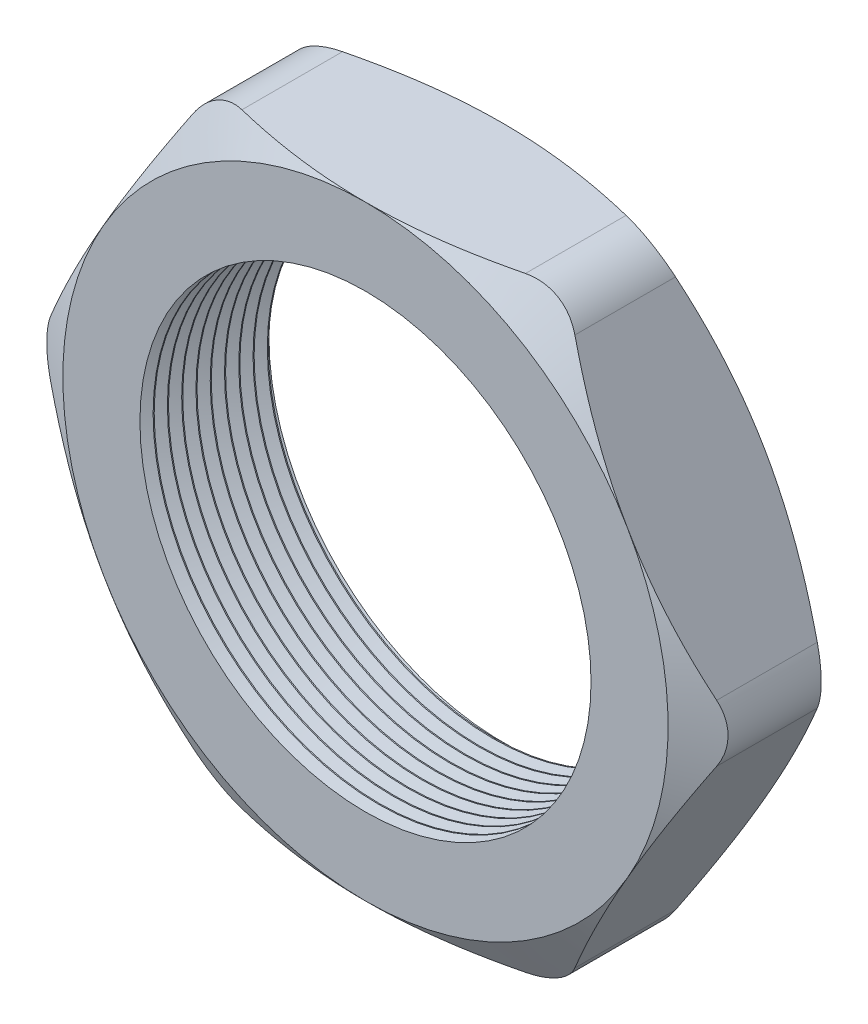
from build123d import *

# Parameters (mm, degrees)
SKETCH1_R          = 10.033
EXTRUDE1_DEPTH     = 6.096
SKETCH2_OUTSIDE_W  = 65.986
SKETCH2_OUTSIDE_H  = 61.82
SKETCH2_OUTSIDE_R  = 13.462
CUT_EXTRUDE1_DEPTH = 7.096
CUT_EXTRUDE1_DRAFT = -60
SKETCH3_OUTSIDE_W  = 65.986
SKETCH3_OUTSIDE_H  = 61.82
SKETCH3_OUTSIDE_R  = 13.462
CUT_EXTRUDE2_DEPTH = 7.096
CUT_EXTRUDE2_DRAFT = -60
FILLET1_R          = 2.54
LPATTERN1_COUNT    = 10
LPATTERN1_PITCH    = 0.635


with BuildPart() as part:
    # Sketch1 → Extrude1 (new body)
    with BuildSketch(Plane.XY):
        Polygon((-15.544578648, 0), (-7.772289324, -13.462), (7.772289324, -13.462), (15.544578648, 0), (7.772289324, 13.462), (-7.772289324, 13.462), align=None)
        Circle(SKETCH1_R, mode=Mode.SUBTRACT)
    extrude(amount=EXTRUDE1_DEPTH)


with BuildPart() as cut_extrude1_tool:
    # Sketch2 outside → Cut-Extrude1 (with draft: the straight prism first)
    with BuildSketch(Plane.XY.offset(6.096)):
        Rectangle(SKETCH2_OUTSIDE_W, SKETCH2_OUTSIDE_H)
        Circle(SKETCH2_OUTSIDE_R, mode=Mode.SUBTRACT)
    extrude(amount=-CUT_EXTRUDE1_DEPTH)
    # Cut-Extrude1: the draft: its side faces are tilted about the plane it starts from
    cut_extrude1_sides = [cut_extrude1_tool.faces().sort_by_distance(p)[0] for p in [
        (0, -30.91, 2.548),
        (32.993, 0, 2.548),
        (0, 30.91, 2.548),
        (-32.993, 0, 2.548),
        (-13.462, 0, 2.548),
    ]]
    draft(cut_extrude1_sides, Plane.XY.offset(6.096), CUT_EXTRUDE1_DRAFT)


with BuildPart() as part_1:
    add(part.part)

    # Cut-Extrude1: cut by cut_extrude1_tool
    add(cut_extrude1_tool.part, mode=Mode.SUBTRACT)


with BuildPart() as cut_extrude2_tool:
    # Sketch3 outside → Cut-Extrude2 (with draft: the straight prism first)
    with BuildSketch(Plane(origin=(0, 0, 0), x_dir=(-1, 0, 0), z_dir=(0, 0, -1))):
        Rectangle(SKETCH3_OUTSIDE_W, SKETCH3_OUTSIDE_H)
        Circle(SKETCH3_OUTSIDE_R, mode=Mode.SUBTRACT)
    extrude(amount=-CUT_EXTRUDE2_DEPTH)
    # Cut-Extrude2: the draft: its side faces are tilted about the plane it starts from
    cut_extrude2_sides = [cut_extrude2_tool.faces().sort_by_distance(p)[0] for p in [
        (0, -30.91, 3.548),
        (-32.993, 0, 3.548),
        (0, 30.91, 3.548),
        (32.993, 0, 3.548),
        (13.462, 0, 3.548),
    ]]
    draft(cut_extrude2_sides, Plane(origin=(0, 0, 0), x_dir=(-1, 0, 0), z_dir=(0, 0, -1)), CUT_EXTRUDE2_DRAFT)


with BuildPart() as part_2:
    add(part_1.part)

    # Cut-Extrude2: cut by cut_extrude2_tool
    add(cut_extrude2_tool.part, mode=Mode.SUBTRACT)

    # Fillet1
    fillet1_edges = [part_2.edges().sort_by_distance(p)[0] for p in [
        (15.544578648, 0, 3.048),
        (7.772289324, -13.462, 3.048),
        (-7.772289324, -13.462, 3.048),
        (-15.544578648, 0, 3.048),
        (-7.772289324, 13.462, 3.048),
        (7.772289324, 13.462, 3.048),
    ]]
    fillet(fillet1_edges, radius=FILLET1_R)

    # Sketch4 → Cut-Revolve1 (revolve, cut)
    with BuildSketch(Plane(origin=(0, 0, 0), x_dir=(1, 0, 0), z_dir=(0, 1, 0)), mode=Mode.PRIVATE) as cut_revolve1_sk:
        Polygon((-10.033, -6.096), (-10.033, -5.509412127), (-10.541, -5.802706063), align=None)
    cut_revolve1 = revolve(cut_revolve1_sk.sketch.rotate(Axis((0, 0, 0), (0, 0, 1)), 180), axis=Axis((0, 0, 0), (0, 0, 1)), mode=Mode.SUBTRACT)  # turned: the seam where the file's is

    # LPattern1: Cut-Revolve1 ×10
    with Locations(*[(0, 0, -i * LPATTERN1_PITCH) for i in range(1, LPATTERN1_COUNT)]):
        add(cut_revolve1, mode=Mode.SUBTRACT)


solid = part_2.part
